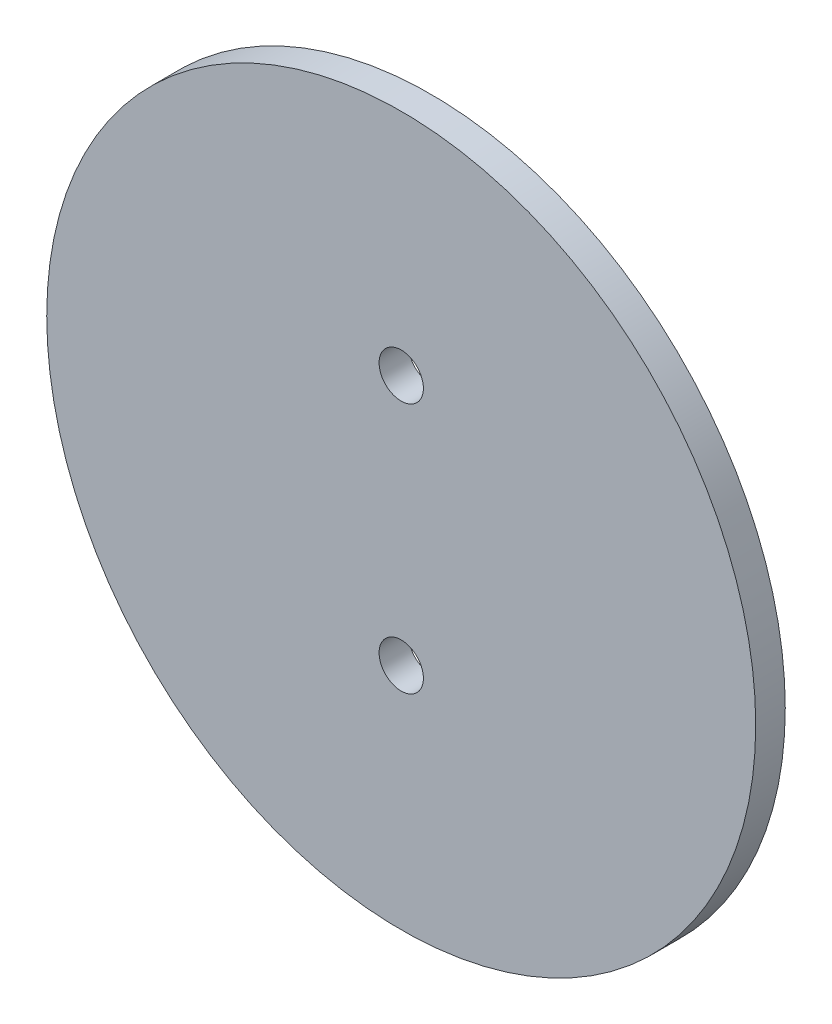
from build123d import *

# Parameters (mm, degrees)
SKETCH1_R           = 76.2
SKETCH1_R_2         = 4.7625
BOSS_EXTRUDE1_DEPTH = 6.35


with BuildPart() as part:
    # Sketch1 → Boss-Extrude1 (new body)
    with BuildSketch(Plane.XY):
        Circle(SKETCH1_R)
        with Locations((0, 26.9875)):
            Circle(SKETCH1_R_2, mode=Mode.SUBTRACT)
        with Locations((0, -26.9875)):
            Circle(SKETCH1_R_2, mode=Mode.SUBTRACT)
    extrude(amount=BOSS_EXTRUDE1_DEPTH)


solid = part.part
